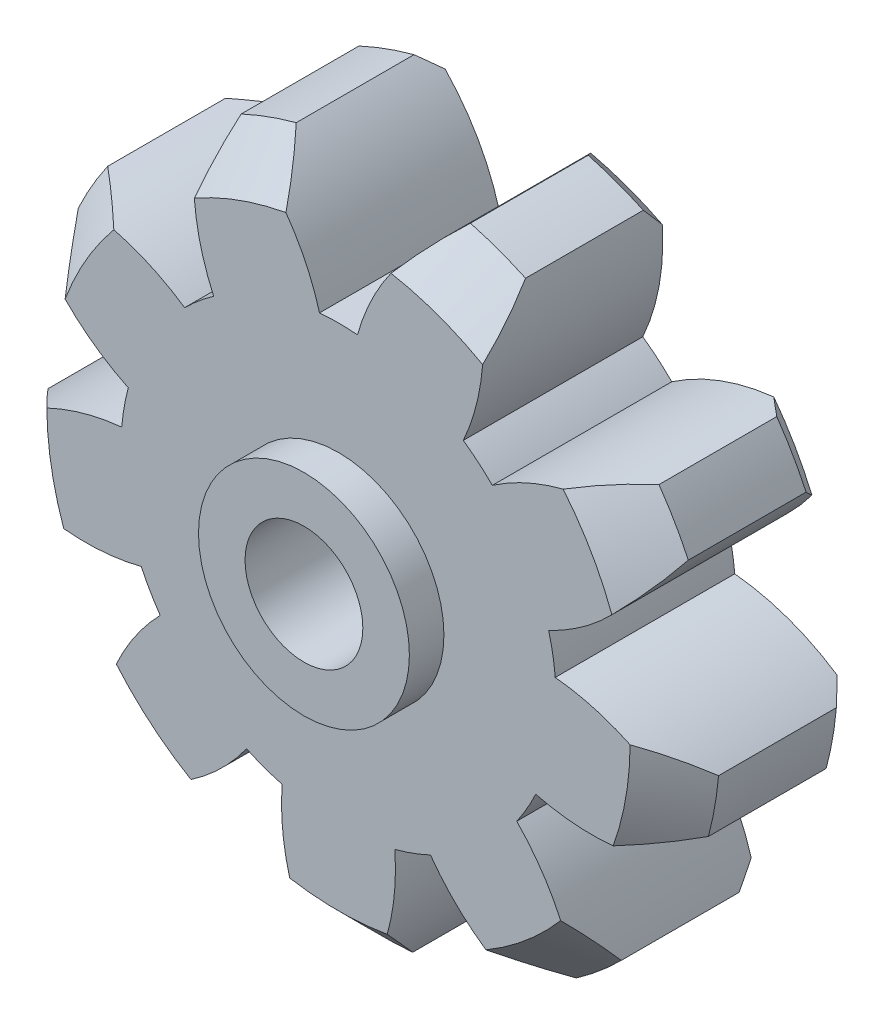
from build123d import *

# Parameters (mm, degrees)
SKETCH1_R               = 15
GEAR_BLANK_DEPTH        = 4
FRONT_GEAR_CHAMFER_SIZE = 2
REAR_GEAR_CHAMFER_SIZE  = 0.75
TOOTH_CUT_DEPTH         = 4
TOOTH_COPIES_COUNT      = 9
SKETCH3_R               = 4.7
BOSS_EXTRUDE1_DEPTH     = 1.54
SKETCH4_R               = 2.625
CUT_EXTRUDE1_DEPTH      = 10


with BuildPart() as part:
    # Sketch1 → Gear Blank (new body, symmetric)
    with BuildSketch(Plane.XY):
        Circle(SKETCH1_R)
    extrude(amount=GEAR_BLANK_DEPTH, both=True)

    # Front Gear Chamfer
    front_gear_chamfer_edges = [part.edges().sort_by_distance(p)[0] for p in [
        (-15, 0, 4),
    ]]
    chamfer(front_gear_chamfer_edges, length=FRONT_GEAR_CHAMFER_SIZE)

    # Rear Gear Chamfer
    rear_gear_chamfer_edges = [part.edges().sort_by_distance(p)[0] for p in [
        (-15, 0, -4),
    ]]
    chamfer(rear_gear_chamfer_edges, length=REAR_GEAR_CHAMFER_SIZE)

    # Sketch2 → Tooth Cut (cut, symmetric)
    with BuildSketch(Plane.XY):
        with BuildLine():
            ThreePointArc((3.882278974, 14.48888919), (-6.939e-06, 15), (-3.882292379, 14.488885598))
            ThreePointArc((-3.882292379, 14.488885598), (-2.012616773, 12.297020546), (-0.845415175, 9.66308818))
            ThreePointArc((-0.845415175, 9.66308818), (-4.487e-06, 9.7), (0.845406235, 9.663088963))
            ThreePointArc((0.845406235, 9.663088963), (2.012605396, 12.297022408), (3.882278974, 14.48888919))
        make_face()
    tooth_cut = extrude(amount=TOOTH_CUT_DEPTH, both=True, mode=Mode.SUBTRACT)

    # Tooth Copies: Tooth Cut ×9 about axis
    tooth_copies_axis = Axis((0, 0, 0), (0, 0, 1))
    for i in range(1, TOOTH_COPIES_COUNT):
        add(tooth_cut.rotate(tooth_copies_axis, i * 360 / TOOTH_COPIES_COUNT), mode=Mode.SUBTRACT)

    # Sketch3 → Boss-Extrude1 (add)
    with BuildSketch(Plane.XY.offset(4)):
        Circle(SKETCH3_R)
    extrude(amount=BOSS_EXTRUDE1_DEPTH)

    # Sketch4 → Cut-Extrude1 (cut)
    with BuildSketch(Plane(origin=(0, 0, -4), x_dir=(-1, 0, 0), z_dir=(0, 0, -1))):
        Circle(SKETCH4_R)
    extrude(amount=-CUT_EXTRUDE1_DEPTH, mode=Mode.SUBTRACT)


solid = part.part
